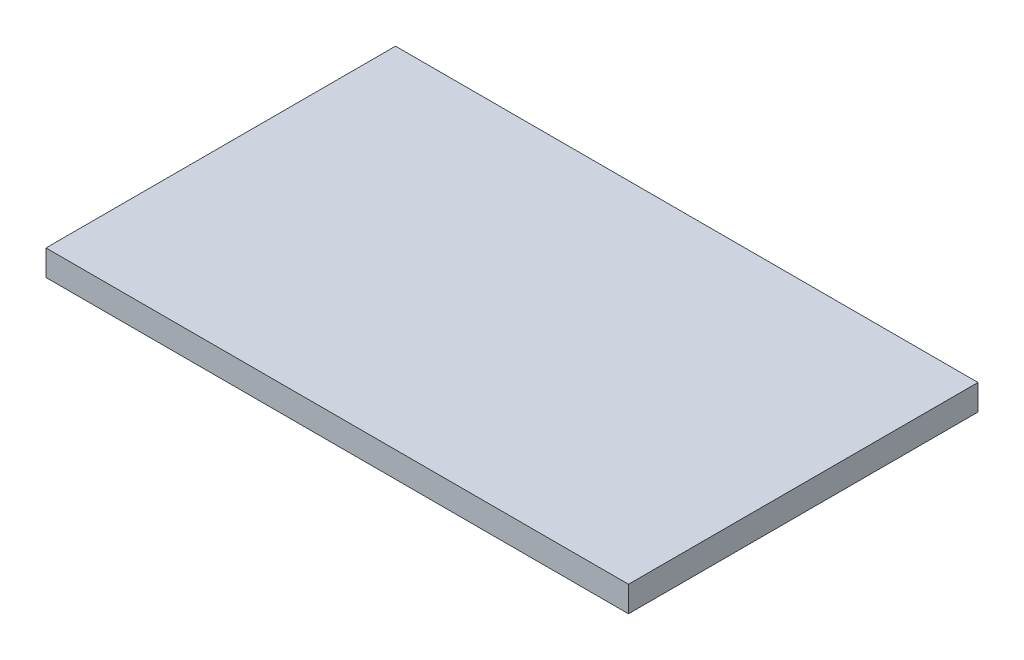
from build123d import *

# Parameters (mm, degrees)
SKETCH1_W           = 125
SKETCH1_H           = 75
BOSS_EXTRUDE2_DEPTH = 5.5


with BuildPart() as part:
    # Sketch1 → Boss-Extrude2 (new body)
    with BuildSketch(Plane(origin=(0, 0, 0), x_dir=(1, 0, 0), z_dir=(0, 1, 0))):
        with Locations((62.5, 37.5)):
            Rectangle(SKETCH1_W, SKETCH1_H)
    extrude(amount=BOSS_EXTRUDE2_DEPTH)


solid = part.part
